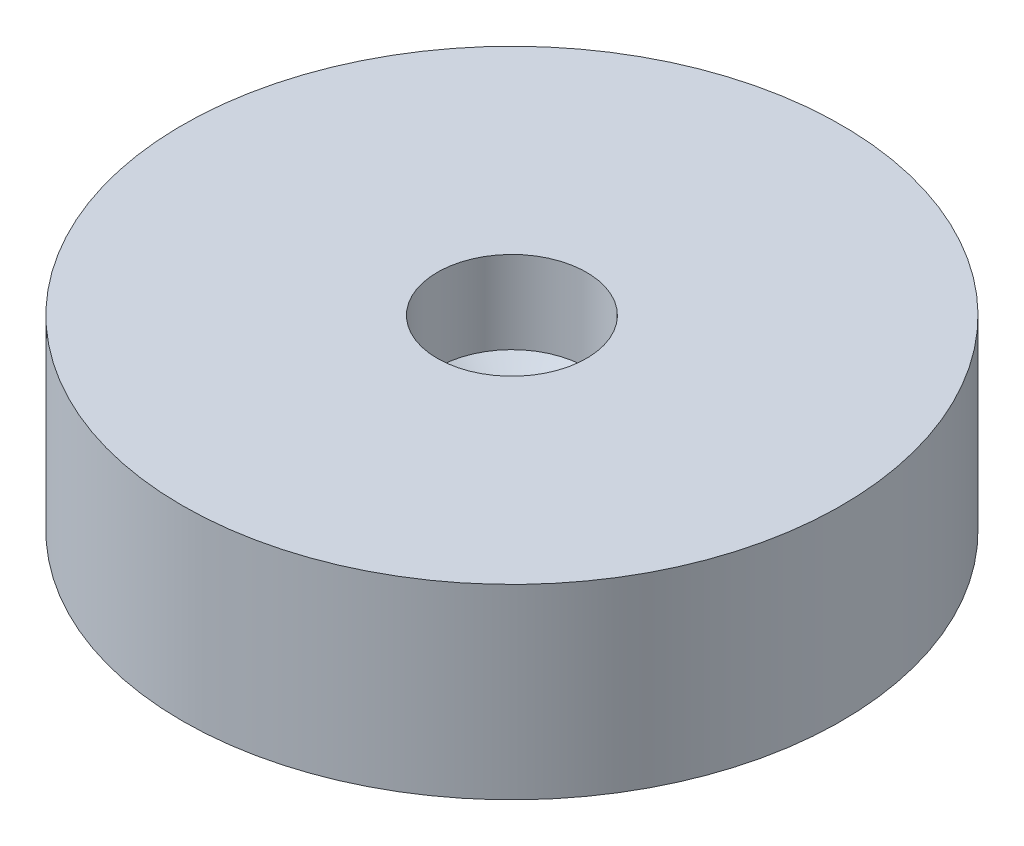
from build123d import *


with BuildPart() as part:
    # Sketch3 → Revolve1 (revolve)
    with BuildSketch(Plane.XY):
        Polygon((3.25, 6.442857143), (6, 8.368427873), (6, 15), (26.5, 15), (26.5, 0), (22, 0), (3.25, 5.442857143), align=None)
    revolve(axis=Axis((0, 0, 0), (0, -1, 0)))


solid = part.part
